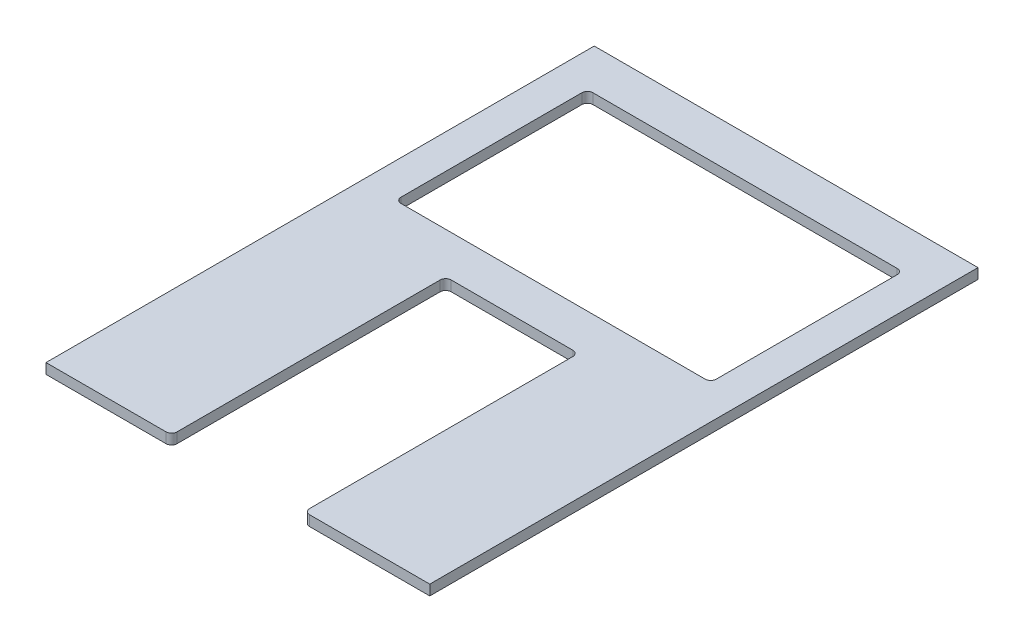
from build123d import *

# Parameters (mm, degrees)
SKETCH1_W           = 146.05
SKETCH1_H           = 88.9
BOSS_EXTRUDE1_DEPTH = 4.7625
FILLET1_R           = 2.54


with BuildPart() as part:
    # Sketch1 → Boss-Extrude1 (new body)
    with BuildSketch(Plane(origin=(0, 0, 0), x_dir=(1, 0, 0), z_dir=(0, 1, 0))):
        Polygon((-30.734, -127), (-30.734, 0), (30.734, 0), (30.734, -127), (88.9, -127), (88.9, 127), (-88.9, 127), (-88.9, -127), align=None)
        with Locations((0, 63.5)):
            Rectangle(SKETCH1_W, SKETCH1_H, mode=Mode.SUBTRACT)
    extrude(amount=BOSS_EXTRUDE1_DEPTH)

    # Fillet1
    fillet1_edges = [part.edges().sort_by_distance(p)[0] for p in [
        (30.734, 2.38125, 127),
        (30.734, 2.38125, 0),
        (-30.734, 2.38125, 0),
        (-30.734, 2.38125, 127),
        (-73.025, 2.38125, -107.95),
        (-73.025, 2.38125, -19.05),
        (73.025, 2.38125, -19.05),
        (73.025, 2.38125, -107.95),
    ]]
    fillet(fillet1_edges, radius=FILLET1_R)


solid = part.part
